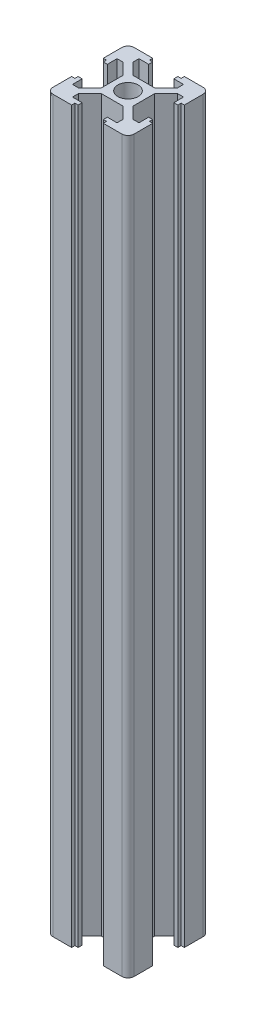
from build123d import *

# Parameters (mm, degrees)
SKETCH1_R           = 2.5
BOSS_EXTRUDE1_DEPTH = 180


with BuildPart() as part:
    # Sketch1 → Boss-Extrude1 (new body)
    with BuildSketch(Plane(origin=(0, 0, 0), x_dir=(1, 0, 0), z_dir=(0, 1, 0))):
        with BuildLine():
            Line((3.9, 10), (8.5, 10))
            ThreePointArc((8.5, 10), (9.560660172, 9.560660172), (10, 8.5))
            Line((10, 8.5), (10, 3.9))
            Line((10, 3.9), (9.2, 3.9))
            Line((9.2, 3.9), (9.2, 3.1))
            Line((9.2, 3.1), (8.2, 3.1))
            Line((8.2, 3.1), (8.2, 5.5))
            Line((8.2, 5.5), (6.77, 5.5))
            Line((6.77, 5.5), (3.9, 2.63))
            Line((3.9, 2.63), (3.9, 0))
            Line((3.9, 0), (3.9, -2.63))
            Line((3.9, -2.63), (6.77, -5.5))
            Line((6.77, -5.5), (8.2, -5.5))
            Line((8.2, -5.5), (8.2, -3.1))
            Line((8.2, -3.1), (9.2, -3.1))
            Line((9.2, -3.1), (9.2, -3.9))
            Line((9.2, -3.9), (10, -3.9))
            Line((10, -3.9), (10, -8.5))
            ThreePointArc((10, -8.5), (9.560660172, -9.560660172), (8.5, -10))
            Line((8.5, -10), (3.9, -10))
            Line((3.9, -10), (3.9, -9.2))
            Line((3.9, -9.2), (3.1, -9.2))
            Line((3.1, -9.2), (3.1, -8.2))
            Line((3.1, -8.2), (5.5, -8.2))
            Line((5.5, -8.2), (5.5, -6.77))
            Line((5.5, -6.77), (2.63, -3.9))
            Line((2.63, -3.9), (0, -3.9))
            Line((0, -3.9), (-2.63, -3.9))
            Line((-2.63, -3.9), (-5.5, -6.77))
            Line((-5.5, -6.77), (-5.5, -8.2))
            Line((-5.5, -8.2), (-3.1, -8.2))
            Line((-3.1, -8.2), (-3.1, -9.2))
            Line((-3.1, -9.2), (-3.9, -9.2))
            Line((-3.9, -9.2), (-3.9, -10))
            Line((-3.9, -10), (-8.5, -10))
            ThreePointArc((-8.5, -10), (-9.560660172, -9.560660172), (-10, -8.5))
            Line((-10, -8.5), (-10, -3.9))
            Line((-10, -3.9), (-9.2, -3.9))
            Line((-9.2, -3.9), (-9.2, -3.1))
            Line((-9.2, -3.1), (-8.2, -3.1))
            Line((-8.2, -3.1), (-8.2, -5.5))
            Line((-8.2, -5.5), (-6.77, -5.5))
            Line((-6.77, -5.5), (-3.9, -2.63))
            Line((-3.9, -2.63), (-3.9, 0))
            Line((-3.9, 0), (-3.9, 2.63))
            Line((-3.9, 2.63), (-6.77, 5.5))
            Line((-6.77, 5.5), (-8.2, 5.5))
            Line((-8.2, 5.5), (-8.2, 3.1))
            Line((-8.2, 3.1), (-9.2, 3.1))
            Line((-9.2, 3.1), (-9.2, 3.9))
            Line((-9.2, 3.9), (-10, 3.9))
            Line((-10, 3.9), (-10, 8.5))
            ThreePointArc((-10, 8.5), (-9.560660172, 9.560660172), (-8.5, 10))
            Line((-8.5, 10), (-3.9, 10))
            Line((-3.9, 10), (-3.9, 9.2))
            Line((-3.9, 9.2), (-3.1, 9.2))
            Line((-3.1, 9.2), (-3.1, 8.2))
            Line((-3.1, 8.2), (-5.5, 8.2))
            Line((-5.5, 8.2), (-5.5, 6.77))
            Line((-5.5, 6.77), (-2.63, 3.9))
            Line((-2.63, 3.9), (2.63, 3.9))
            Line((2.63, 3.9), (5.5, 6.77))
            Line((5.5, 6.77), (5.5, 8.2))
            Line((5.5, 8.2), (3.1, 8.2))
            Line((3.1, 8.2), (3.1, 9.2))
            Line((3.1, 9.2), (3.9, 9.2))
            Line((3.9, 9.2), (3.9, 10))
        make_face()
        Circle(SKETCH1_R, mode=Mode.SUBTRACT)
    extrude(amount=BOSS_EXTRUDE1_DEPTH)


solid = part.part
